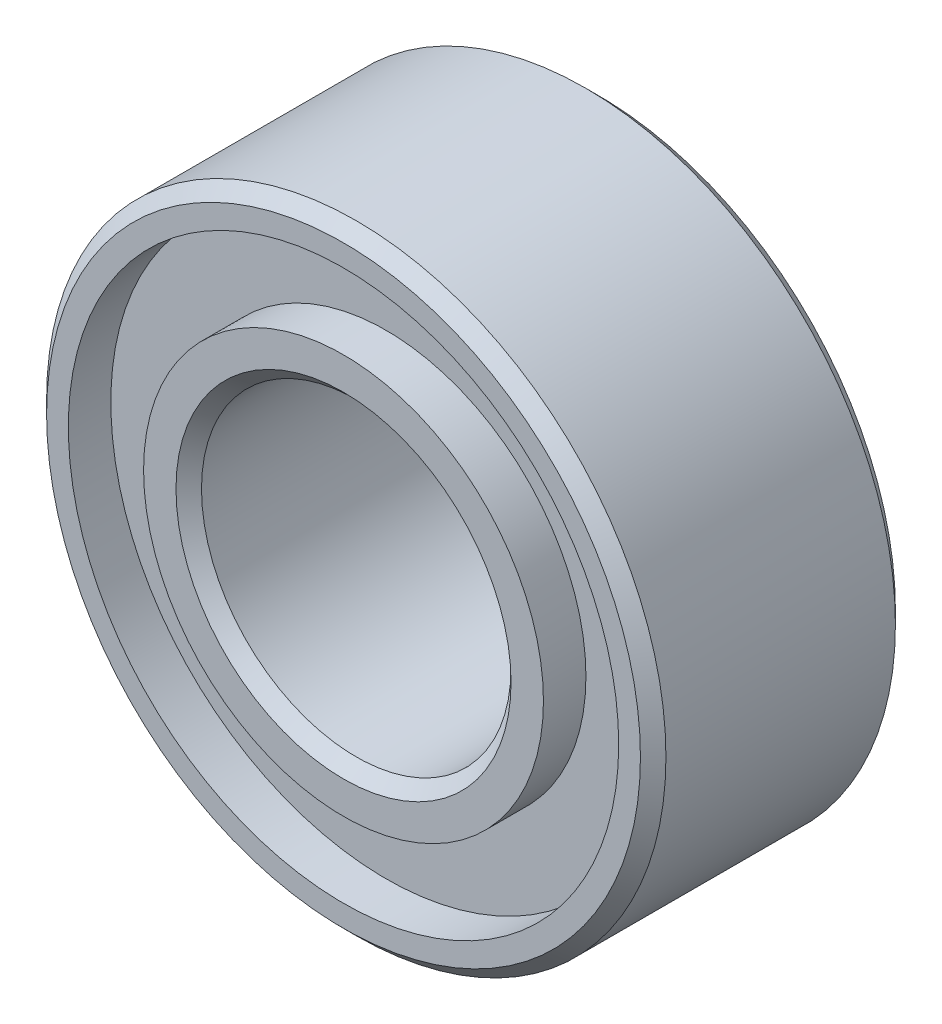
from build123d import *

# Parameters (mm, degrees)
SKETCH1_R      = 6
EXTRUDE1_DEPTH = 4.94
HOLE1_D        = 10.6635
HOLE1_DEPTH    = 0.823333333
SKETCH4_R      = 3.873625
EXTRUDE2_DEPTH = 0.823333333
HOLE2_D        = 10.6635
HOLE2_DEPTH    = 0.823333333
SKETCH7_R      = 3.873625
EXTRUDE3_DEPTH = 0.823333333
HOLE3_D        = 5.9975
HOLE3_DEPTH    = 4.94
CHAMFER1_SIZE  = 0.247


with BuildPart() as part:
    # Sketch1 → Extrude1 (new body)
    with BuildSketch(Plane.XY.offset(4.94)):
        Circle(SKETCH1_R)
    extrude(amount=-EXTRUDE1_DEPTH)

    # Hole1
    with Locations(Plane.XY.offset(4.94)):
        with Locations((0, 0)):
            Hole(HOLE1_D / 2, depth=HOLE1_DEPTH)

    # Sketch4 → Extrude2 (add)
    with BuildSketch(Plane.XY.offset(4.116666667)):
        Circle(SKETCH4_R)
    extrude(amount=EXTRUDE2_DEPTH)

    # Hole2
    with Locations(Plane(origin=(0, 0, 0), x_dir=(-1, 0, 0), z_dir=(0, 0, -1))):
        with Locations((0, 0)):
            Hole(HOLE2_D / 2, depth=HOLE2_DEPTH)

    # Sketch7 → Extrude3 (add)
    with BuildSketch(Plane(origin=(0, 0, 0.823333333), x_dir=(-1, 0, 0), z_dir=(0, 0, -1))):
        Circle(SKETCH7_R)
    extrude(amount=EXTRUDE3_DEPTH)

    # Hole3
    with Locations(Plane(origin=(0, 0, 0), x_dir=(-1, 0, 0), z_dir=(0, 0, -1))):
        with Locations((0, 0)):
            Hole(HOLE3_D / 2, depth=HOLE3_DEPTH)

    # Chamfer1
    chamfer1_edges = [part.edges().sort_by_distance(p)[0] for p in [
        (-6, 0, 4.94),
        (-2.99875, 0, 0),
        (-2.99875, 0, 4.94),
        (-6, 0, 0),
    ]]
    chamfer(chamfer1_edges, length=CHAMFER1_SIZE)


solid = part.part
